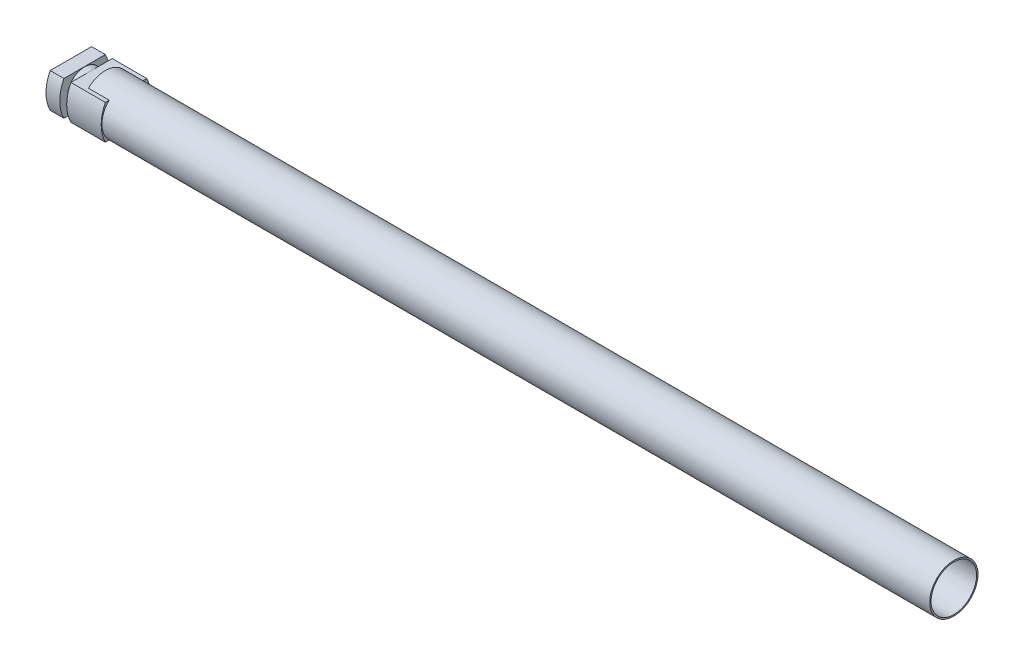
from build123d import *

# Parameters (mm, degrees)
BOSS_EXTRUDE1_DEPTH = 101.6
SKETCH2_W           = 12.7
SKETCH2_H           = 25.4
SKETCH3_R           = 44.45
SKETCH3_R_2         = 41.91
BOSS_EXTRUDE2_DEPTH = 1524
BOSS_EXTRUDE3_START = -38.1
SKETCH3_2_R         = 44.45
SKETCH3_2_R_2       = 41.91
BOSS_EXTRUDE3_DEPTH = 38.1


with BuildPart() as part:
    # Sketch1 → Boss-Extrude1 (new body)
    with BuildSketch(Plane(origin=(0, 0, 0), x_dir=(0, 0, -1), z_dir=(1, 0, 0))):
        with BuildLine():
            Line((-38.1, 31.75), (38.1, 31.75))
            ThreePointArc((38.1, 31.75), (45.764257606, 0), (38.1, -31.75))
            Line((38.1, -31.75), (-38.1, -31.75))
            ThreePointArc((-38.1, -31.75), (-45.764257606, 0), (-38.1, 31.75))
        make_face()
    extrude(amount=BOSS_EXTRUDE1_DEPTH)

    # Sketch2 → Cut-Revolve1 (revolve, cut)
    with BuildSketch(Plane.XY):
        with Locations((31.75, 44.034385241)):
            Rectangle(SKETCH2_W, SKETCH2_H)
    revolve(axis=Axis((-7.218985368, 0, 0), (1, 0, 0)), mode=Mode.SUBTRACT)

    # Sketch3 → Boss-Extrude2 (add)
    with BuildSketch(Plane(origin=(101.6, 0, 0), x_dir=(0, 0, -1), z_dir=(1, 0, 0))):
        Circle(SKETCH3_R)
        Circle(SKETCH3_R_2, mode=Mode.SUBTRACT)
    extrude(amount=BOSS_EXTRUDE2_DEPTH)

    # Sketch3_2 → Boss-Extrude3 (add)
    with BuildSketch(Plane(origin=(101.6, 0, 0), x_dir=(0, 0, -1), z_dir=(1, 0, 0)).offset(BOSS_EXTRUDE3_START)):
        Circle(SKETCH3_2_R)
        Circle(SKETCH3_2_R_2, mode=Mode.SUBTRACT)
    extrude(amount=BOSS_EXTRUDE3_DEPTH)


solid = part.part
